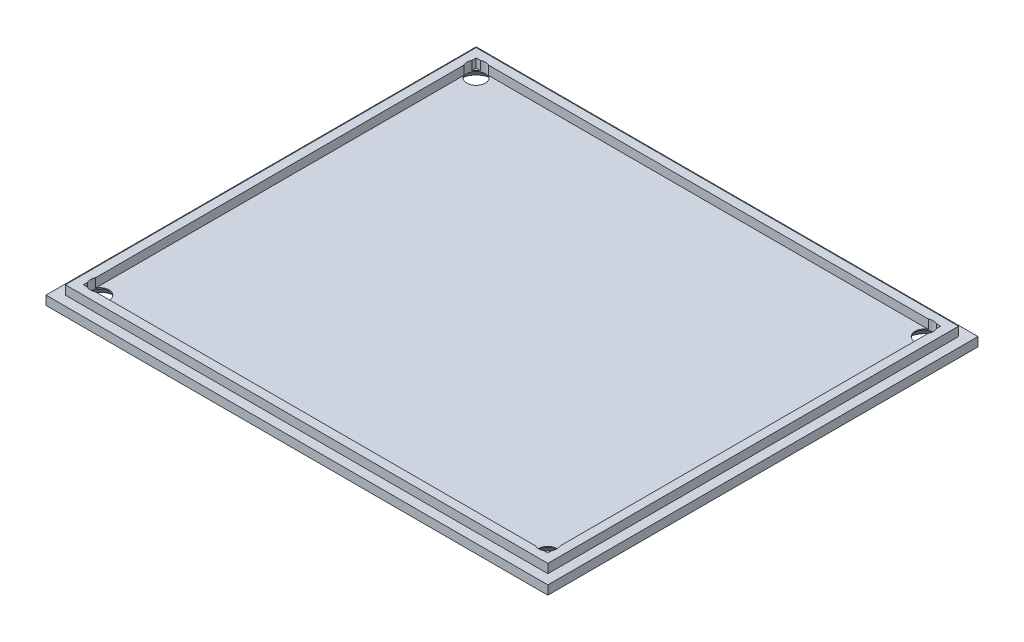
from build123d import *

# Parameters (mm, degrees)
SKETCH1_W                                      = 88.9
SKETCH1_H                                      = 76.2
BOSS_EXTRUDE1_DEPTH                            = 1.5875
SKETCH2_W                                      = 85.471
SKETCH2_H                                      = 72.771
SKETCH2_W_2                                    = 82.296
SKETCH2_H_2                                    = 69.596
BOSS_EXTRUDE2_DEPTH                            = 1.5875
CSK_FOR_4_FLAT_HEAD_MACHINE_SCREW1_D           = 3.2639
CSK_FOR_4_FLAT_HEAD_MACHINE_SCREW1_CSINK_D     = 5.715
CSK_FOR_4_FLAT_HEAD_MACHINE_SCREW1_CSINK_ANGLE = 82


with BuildPart() as part:
    # Sketch1 → Boss-Extrude1 (new body)
    with BuildSketch(Plane(origin=(0, 0, 0), x_dir=(1, 0, 0), z_dir=(0, 1, 0))):
        Rectangle(SKETCH1_W, SKETCH1_H)
    extrude(amount=BOSS_EXTRUDE1_DEPTH)

    # Sketch2 → Boss-Extrude2 (add)
    with BuildSketch(Plane(origin=(0, 1.5875, 0), x_dir=(1, 0, 0), z_dir=(0, 1, 0))):
        Rectangle(SKETCH2_W, SKETCH2_H)
        Rectangle(SKETCH2_W_2, SKETCH2_H_2, mode=Mode.SUBTRACT)
    extrude(amount=BOSS_EXTRUDE2_DEPTH)

    # CSK for #4 Flat Head Machine Screw1 (through all)
    with Locations(Plane(origin=(28.481877995, 0, -59.395517913), x_dir=(-1, 0, 0), z_dir=(0, -1, 0))):
        with Locations((-11.205622005, -26.058017913), (68.169377995, -26.058017913), (68.169377995, -92.733017913), (-11.205622005, -92.733017913)):
            CounterSinkHole(CSK_FOR_4_FLAT_HEAD_MACHINE_SCREW1_D / 2, CSK_FOR_4_FLAT_HEAD_MACHINE_SCREW1_CSINK_D / 2, counter_sink_angle=CSK_FOR_4_FLAT_HEAD_MACHINE_SCREW1_CSINK_ANGLE)


solid = part.part
